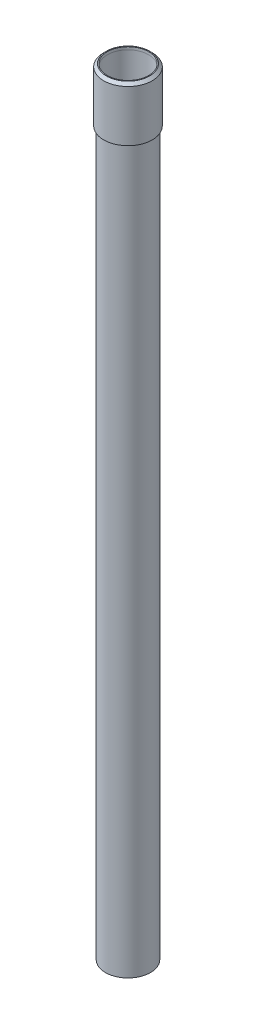
from build123d import *

# Parameters (mm, degrees)
SKETCH1_R      = 12.5
SKETCH1_R_2    = 11.5
EXTRUDE1_DEPTH = 215
CHAMFER1_SIZE  = 1.5


with BuildPart() as part:
    # Sketch1 → Extrude1 (new body, symmetric)
    with BuildSketch(Plane(origin=(0, 0, 0), x_dir=(1, 0, 0), z_dir=(0, 1, 0))):
        Circle(SKETCH1_R)
        Circle(SKETCH1_R_2, mode=Mode.SUBTRACT)
    extrude(amount=EXTRUDE1_DEPTH, both=True)


with BuildPart() as body_2:
    # Sketch2 → Revolve1 (revolve)
    with BuildSketch(Plane.XY):
        Polygon((13.5, 216.5), (13.5, 186.5), (12.5, 186.5), (12.5, 215), (11.5, 215), (11.5, 216.5), align=None)
    revolve(axis=Axis((0, 224.324804611, 0), (0, -1, 0)))

    # Chamfer1
    chamfer1_edges = [body_2.edges().sort_by_distance(p)[0] for p in [
        (-13.5, 216.5, 0),
    ]]
    chamfer(chamfer1_edges, length=CHAMFER1_SIZE)


solid = Compound([part.part, body_2.part])
